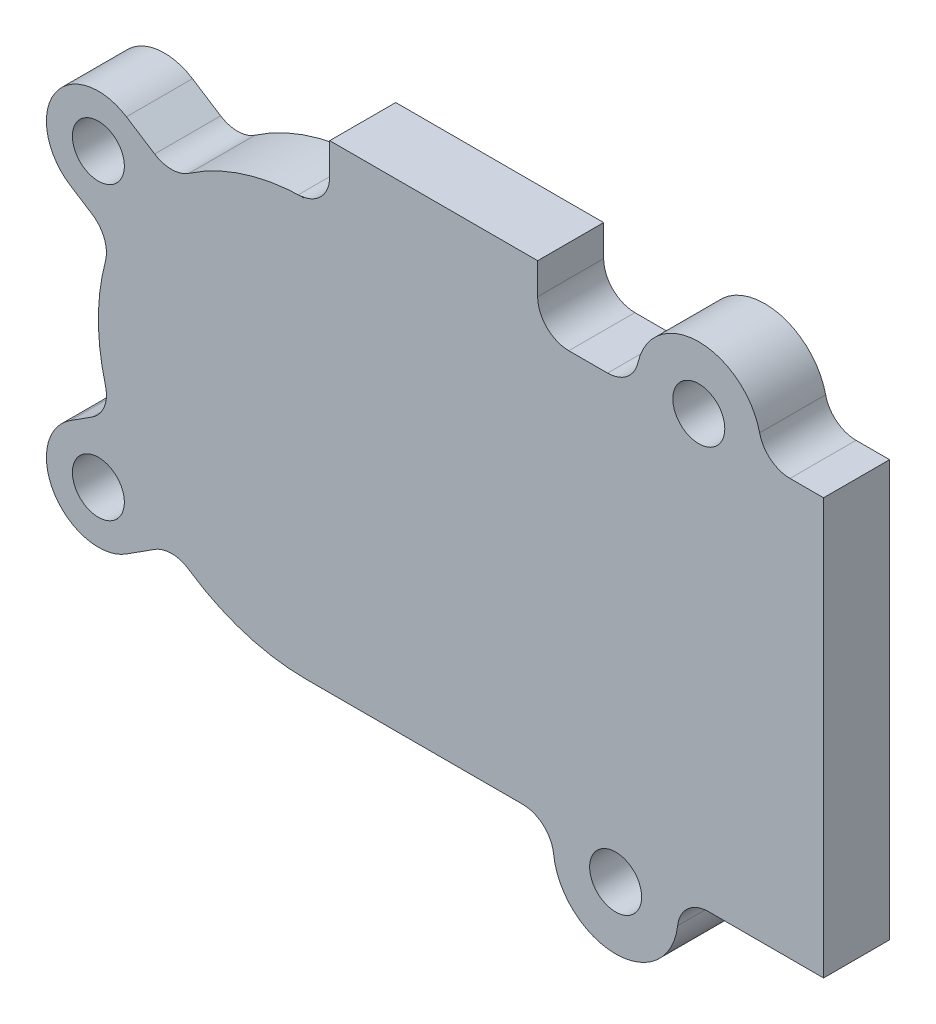
from build123d import *

# Parameters (mm, degrees)
SKETCH1_R               = 2.5
BOSS_EXTRUDE1_DEPTH     = 6.35
SKETCH12_W              = 20
SKETCH12_H              = 6.35
BOSS_EXTRUDE2_DEPTH     = 6
FILLET2_R               = 3
CUT_EXTRUDE9_DEPTH      = 48.228937104
CUT_EXTRUDE9_DEPTH_BACK = 48.228937104
SKETCH13_R              = 2.5
FILLET1_R               = 3


with BuildPart() as part:
    # Sketch1 → Boss-Extrude1 (new body)
    with BuildSketch(Plane.XY):
        with BuildLine():
            Line((-37.5, -20), (11.5, -20))
            Line((11.5, -20), (11.5, -22))
            ThreePointArc((11.5, -22), (17.5, -28), (23.5, -22))
            Line((23.5, -22), (23.5, -20))
            Line((23.5, -20), (37.5, -20))
            Line((37.5, -20), (37.5, 20))
            Line((37.5, 20), (31.5, 20))
            Line((31.5, 20), (31.5, 21))
            ThreePointArc((31.5, 21), (25.5, 27), (19.5, 21))
            Line((19.5, 21), (19.5, 20))
            Line((19.5, 20), (-37.5, 20))
            Line((-37.5, 20), (-37.5, -20))
        make_face()
        with Locations((25.5, 21)):
            Circle(SKETCH1_R, mode=Mode.SUBTRACT)
        with Locations((17.5, -22)):
            Circle(SKETCH1_R, mode=Mode.SUBTRACT)
    extrude(amount=BOSS_EXTRUDE1_DEPTH)

    # Sketch12 → Boss-Extrude2 (add)
    with BuildSketch(Plane(origin=(0, 20, 0), x_dir=(1, 0, 0), z_dir=(0, 1, 0))):
        with Locations((0, -3.175)):
            Rectangle(SKETCH12_W, SKETCH12_H)
    extrude(amount=BOSS_EXTRUDE2_DEPTH)

    # Fillet2
    fillet2_edges = [part.edges().sort_by_distance(p)[0] for p in [
        (-10, 20, 3.175),
        (10, 20, 3.175),
    ]]
    fillet(fillet2_edges, radius=FILLET2_R)

    # Sketch13 → Cut-Extrude9 (cut, two sides: drawn at the far end of the back side and taken through both)
    with BuildSketch(Plane.XY.offset(6.35).offset(-CUT_EXTRUDE9_DEPTH_BACK)):
        with BuildLine():
            Line((-12.25, 20), (-37.5, 20))
            Line((-37.5, 20), (-37.5, -20))
            Line((-37.5, -20), (-12.25, -20))
            ThreePointArc((-12.25, -20), (-19.075859236, -18.799139494), (-25.082027993, -15.34076457))
            Line((-25.082027993, -15.34076457), (-29.549349609, -18.20790773))
            ThreePointArc((-29.549349609, -18.20790773), (-36.45790773, -16.700650391), (-34.950650391, -9.79209227))
            Line((-34.950650391, -9.79209227), (-30.909610133, -7.198538025))
            ThreePointArc((-30.909610133, -7.198538025), (-32.25, 0), (-30.909610133, 7.198538025))
            Line((-30.909610133, 7.198538025), (-34.950650391, 9.79209227))
            ThreePointArc((-34.950650391, 9.79209227), (-36.45790773, 16.700650391), (-29.549349609, 18.20790773))
            Line((-29.549349609, 18.20790773), (-25.082027993, 15.34076457))
            ThreePointArc((-25.082027993, 15.34076457), (-19.075859236, 18.799139494), (-12.25, 20))
        make_face()
        with Locations((-32.25, 14)):
            Circle(SKETCH13_R)
        with Locations((-32.25, -14)):
            Circle(SKETCH13_R)
    extrude(amount=CUT_EXTRUDE9_DEPTH + CUT_EXTRUDE9_DEPTH_BACK, mode=Mode.SUBTRACT)

    # Fillet1
    fillet1_edges = [part.edges().sort_by_distance(p)[0] for p in [
        (11.5, -20, 3.175),
        (23.5, -20, 3.175),
        (31.5, 20, 3.175),
        (19.5, 20, 3.175),
        (-25.082027993, -15.34076457, 3.175),
        (-25.082027993, 15.34076457, 3.175),
        (-30.909610133, -7.198538025, 3.175),
        (-30.909610133, 7.198538025, 3.175),
    ]]
    fillet(fillet1_edges, radius=FILLET1_R)


solid = part.part
